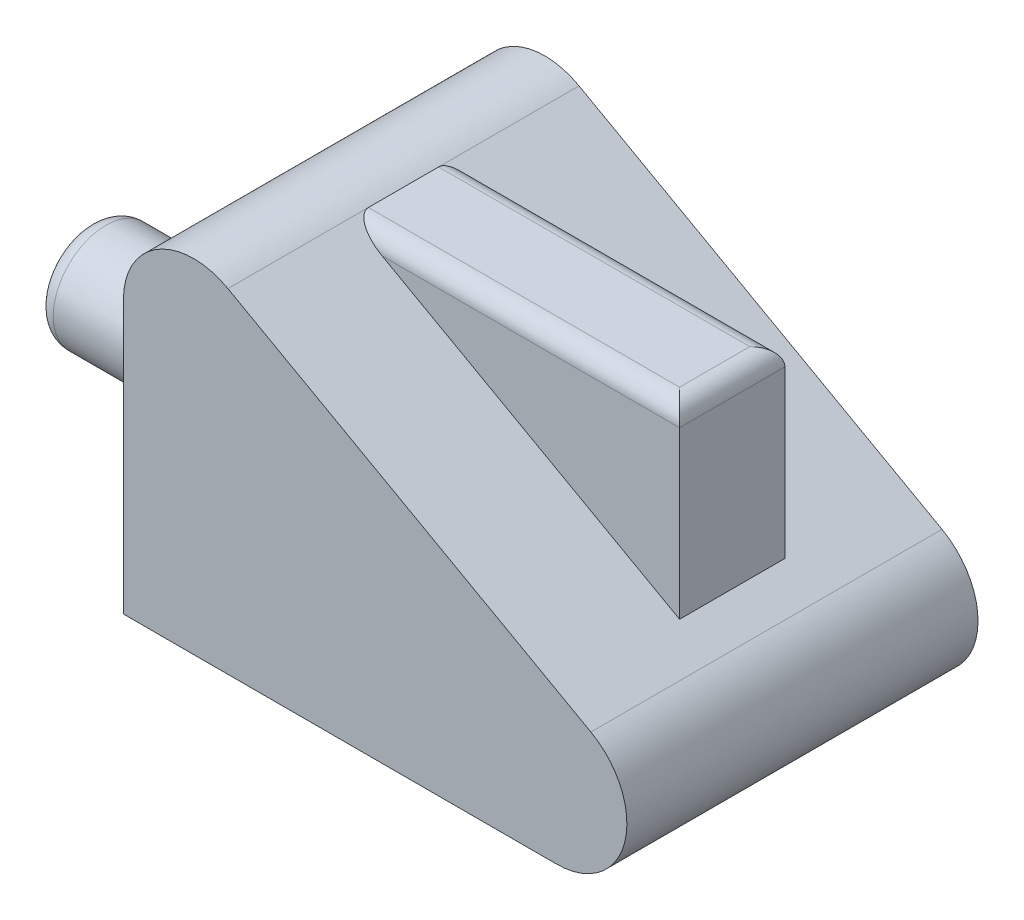
from build123d import *

# Parameters (mm, degrees)
BOSS_EXTRUDE1_DEPTH = 5
SKETCH2_W           = 6.952682296
SKETCH2_H           = 2.551538718
SKETCH2_R           = 0.75
CUT_EXTRUDE1_DEPTH  = 3
SKETCH3_W           = 4.68163698
SKETCH3_H           = 1.5
BOSS_EXTRUDE2_DEPTH = 4.757403
FILLET1_R           = 0.25
FILLET2_R           = 0.25


with BuildPart() as part:
    # Sketch1 → Boss-Extrude1 (new body)
    with BuildSketch(Plane.XY):
        with BuildLine():
            Line((0, 2.17), (-3, 2.17))
            Line((-3, 2.17), (-3, 0.67))
            Line((-3, 0.67), (0, 0.67))
            Line((0, 0.67), (0, 0))
            Line((0, 0), (6.168897591, 0))
            ThreePointArc((6.168897591, 0), (7.13669318, 0.748262641), (6.656158202, 1.873256604))
            Line((6.656158202, 1.873256604), (1.487260611, 4.757403357))
            ThreePointArc((1.487260611, 4.757403357), (0.49367037, 4.74648677), (0, 3.884146753))
            Line((0, 3.884146753), (0, 2.17))
        make_face()
    extrude(amount=BOSS_EXTRUDE1_DEPTH)

    # Sketch2 → Cut-Extrude1 (cut)
    with BuildSketch(Plane.ZY.offset(3)):
        with Locations((2.401285903, 1.467822219)):
            Rectangle(SKETCH2_W, SKETCH2_H)
        with Locations((2.5, 1.42)):
            Circle(SKETCH2_R, mode=Mode.SUBTRACT)
    extrude(amount=-CUT_EXTRUDE1_DEPTH, mode=Mode.SUBTRACT)

    # Sketch3 → Boss-Extrude2 (add)
    with BuildSketch(Plane.XZ):
        with Locations((3.828079101, 2.5)):
            Rectangle(SKETCH3_W, SKETCH3_H)
    extrude(amount=-BOSS_EXTRUDE2_DEPTH)

    # Fillet1
    fillet1_edges = [part.edges().sort_by_distance(p)[0] for p in [
        (-3, 1.42, 1.75),
    ]]
    fillet(fillet1_edges, radius=FILLET1_R)

    # Fillet2
    fillet2_edges = [part.edges().sort_by_distance(p)[0] for p in [
        (3.828079101, 4.757403, 1.75),
        (3.828079101, 4.757403, 3.25),
        (6.168897591, 4.757403, 2.5),
    ]]
    fillet(fillet2_edges, radius=FILLET2_R)


solid = part.part
